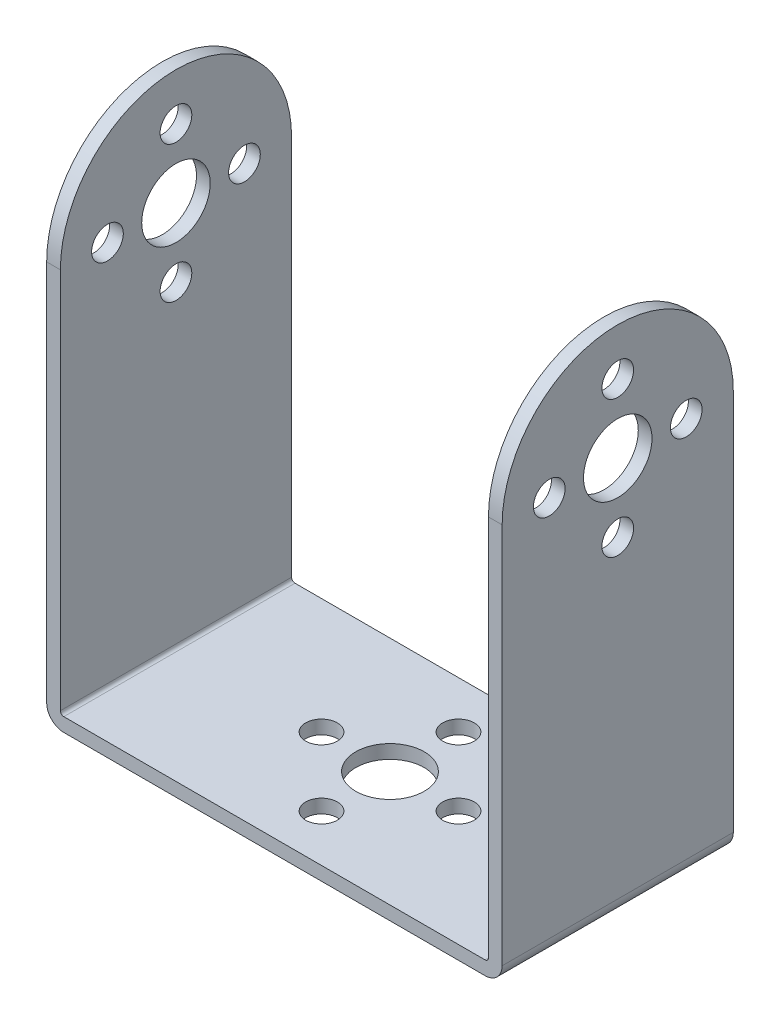
from build123d import *

# Parameters (mm, degrees)
BOSS_EXTRUDE1_DEPTH            = 53.2
SKETCH2_W                      = 50
SKETCH2_H                      = 63.5
CUT_EXTRUDE1_DEPTH             = 28
F_8_0_8_DIAMETER_HOLE1_D       = 8
F_8_0_8_DIAMETER_HOLE1_DEPTH   = 1.6
F_3_7_3_7_DIAMETER_HOLE1_D     = 3.7
F_3_7_3_7_DIAMETER_HOLE2_D     = 3.7
F_3_7_3_7_DIAMETER_HOLE2_DEPTH = 1.6
F_8_0_8_DIAMETER_HOLE2_D       = 8
F_8_0_8_DIAMETER_HOLE2_DEPTH   = 1.6
F_8_0_8_DIAMETER_HOLE3_D       = 8
F_8_0_8_DIAMETER_HOLE3_DEPTH   = 1.6
FILLET1_R                      = 0.4
FILLET2_R                      = 2


with BuildPart() as part:
    # Sketch1 → Boss-Extrude1 (new body)
    with BuildSketch(Plane(origin=(26.6, 0, 0), x_dir=(0, 0, -1), z_dir=(1, 0, 0))):
        with BuildLine():
            Line((-13.5, 45), (-13.5, -1.6))
            Line((-13.5, -1.6), (13.5, -1.6))
            Line((13.5, -1.6), (13.5, 45))
            ThreePointArc((13.5, 45), (0, 58.5), (-13.5, 45))
        make_face()
    extrude(amount=-BOSS_EXTRUDE1_DEPTH)

    # Sketch2 → Cut-Extrude1 (cut, through all)
    with BuildSketch(Plane(origin=(0, 0, -13.5), x_dir=(-1, 0, 0), z_dir=(0, 0, -1))):
        with Locations((0, 31.75)):
            Rectangle(SKETCH2_W, SKETCH2_H)
    extrude(amount=-CUT_EXTRUDE1_DEPTH, mode=Mode.SUBTRACT)

    # Ø8.0 (8) Diameter Hole1
    with Locations(Plane.ZY.offset(26.6)):
        with Locations((0, 45)):
            Hole(F_8_0_8_DIAMETER_HOLE1_D / 2, depth=F_8_0_8_DIAMETER_HOLE1_DEPTH)

    # Ø3.7 (3.7) Diameter Hole1 (through all)
    with Locations(Plane.ZY.offset(26.6)):
        with Locations((0, 53), (-8, 45), (0, 37), (8, 45)):
            Hole(F_3_7_3_7_DIAMETER_HOLE1_D / 2)

    # Ø3.7 (3.7) Diameter Hole2
    with Locations(Plane(origin=(0, 0, 0), x_dir=(1, 0, 0), z_dir=(0, 1, 0))):
        with Locations((0, 8), (8, 0), (0, -8), (-8, 0)):
            Hole(F_3_7_3_7_DIAMETER_HOLE2_D / 2, depth=F_3_7_3_7_DIAMETER_HOLE2_DEPTH)

    # Ø8.0 (8) Diameter Hole2
    with Locations(Plane(origin=(0, 0, 0), x_dir=(1, 0, 0), z_dir=(0, 1, 0))):
        with Locations((0, 0)):
            Hole(F_8_0_8_DIAMETER_HOLE2_D / 2, depth=F_8_0_8_DIAMETER_HOLE2_DEPTH)

    # Ø8.0 (8) Diameter Hole3
    with Locations(Plane(origin=(26.6, 0, 0), x_dir=(0, 0, -1), z_dir=(1, 0, 0))):
        with Locations((0, 45)):
            Hole(F_8_0_8_DIAMETER_HOLE3_D / 2, depth=F_8_0_8_DIAMETER_HOLE3_DEPTH)

    # Fillet1
    fillet1_edges = [part.edges().sort_by_distance(p)[0] for p in [
        (-25, 0, 0),
        (25, 0, 0),
    ]]
    fillet(fillet1_edges, radius=FILLET1_R)

    # Fillet2
    fillet2_edges = [part.edges().sort_by_distance(p)[0] for p in [
        (-26.6, -1.6, 0),
        (26.6, -1.6, 0),
    ]]
    fillet(fillet2_edges, radius=FILLET2_R)


solid = part.part
